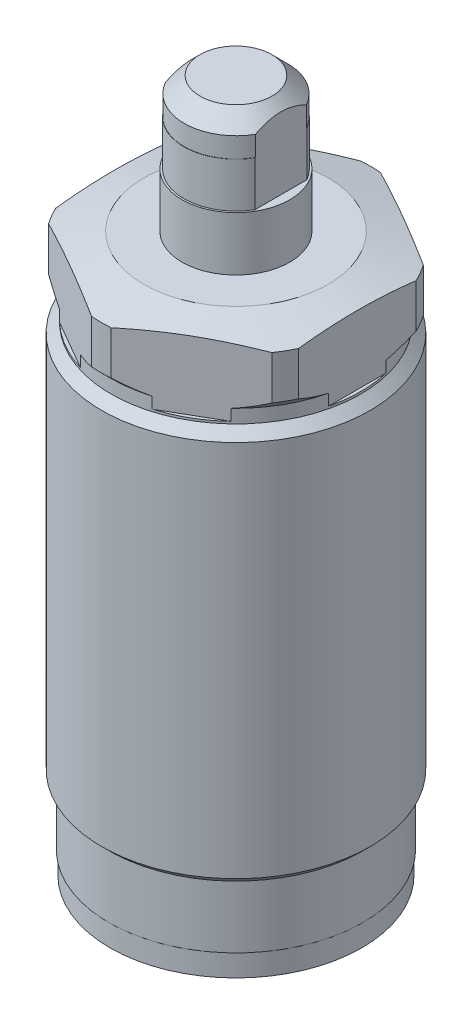
from build123d import *

# Parameters (mm, degrees)
SKETCH1_R          = 15
STOCK_DEPTH        = 29.75
HEX_HEAD_DEPTH     = 8.5
SKETCH5_R          = 14
RETAINER_DEPTH     = 2.5
SKETCH9_W          = 1.368260999
SKETCH9_H          = 3.99
SKETCH9_W_2        = 1.545391276
CUT_EXTRUDE3_DEPTH = 13.475
SKETCH10_R         = 5.98
EXTRUDE4_DEPTH     = 11.01
SKETCH11_R         = 5.98
SKETCH11_R_2       = 5.775
CUT_EXTRUDE4_DEPTH = 5
SKETCH13_W         = 0.98
SKETCH13_H         = 5
CUT_EXTRUDE5_DEPTH = 15


with BuildPart() as part:
    # Sketch1 → STOCK (new body, symmetric)
    with BuildSketch(Plane(origin=(0, 0, 0), x_dir=(1, 0, 0), z_dir=(0, 1, 0))):
        with Locations(Location((0, 0, 0), (0, 0, 270))):  # turned: the seam where the file's is
            Circle(SKETCH1_R)
    extrude(amount=STOCK_DEPTH, both=True)

    # Sketch2 → HEX_HEAD (cut)
    with BuildSketch(Plane(origin=(0, 29.75, 0), x_dir=(1, 0, 0), z_dir=(0, 1, 0))):
        with BuildLine():
            ThreePointArc((12.412375826, 8.422168743), (7.5, 12.990381057), (1.087624174, 14.960517159))
            Line((1.087624174, 14.960517159), (12.412375826, 8.422168743))
        make_face()
        with BuildLine():
            Line((-12.412375826, 8.422168743), (-1.087624174, 14.960517159))
            ThreePointArc((-1.087624174, 14.960517159), (-7.5, 12.990381057), (-12.412375826, 8.422168743))
        make_face()
        with BuildLine():
            Line((13.5, 6.538348415), (13.5, -6.538348415))
            ThreePointArc((13.5, -6.538348415), (15, 0), (13.5, 6.538348415))
        make_face()
        with BuildLine():
            Line((-13.5, -6.538348415), (-13.5, 6.538348415))
            ThreePointArc((-13.5, 6.538348415), (-15, 0), (-13.5, -6.538348415))
        make_face()
        with BuildLine():
            Line((12.412375826, -8.422168743), (1.087624174, -14.960517159))
            ThreePointArc((1.087624174, -14.960517159), (7.5, -12.990381057), (12.412375826, -8.422168743))
        make_face()
        with BuildLine():
            Line((-1.087624174, -14.960517159), (-12.412375826, -8.422168743))
            ThreePointArc((-12.412375826, -8.422168743), (-7.5, -12.990381057), (-1.087624174, -14.960517159))
        make_face()
    extrude(amount=-HEX_HEAD_DEPTH, mode=Mode.SUBTRACT)

    # Sketch3 → CROWN (revolve, cut)
    with BuildSketch(Plane.XY, mode=Mode.PRIVATE) as crown_sk:
        Polygon((10.25, 29.75), (15, 29.75), (15, 28.477241336), align=None)
    revolve(crown_sk.sketch.rotate(Axis((0, 0, 0), (0, 1, 0)), 94.158067237), axis=Axis((0, 0, 0), (0, 1, 0)), mode=Mode.SUBTRACT)  # turned: the seam where the file's is

    # Sketch4 → Cut-Revolve1 (revolve, cut)
    with BuildSketch(Plane.XY, mode=Mode.PRIVATE) as cut_revolve1_sk:
        Polygon((14.125, -29.75), (16.897307641, -29.75), (16.897307641, 25.522307641), (13.875, 22.5), (13.875, 21), (14.925, 19.95), (14.925, -22.04), (14.125, -22.84), align=None)
    revolve(cut_revolve1_sk.sketch.rotate(Axis((0, -34.538461529, 0), (0, 1, 0)), 90), axis=Axis((0, -34.538461529, 0), (0, 1, 0)), mode=Mode.SUBTRACT)  # turned: the seam where the file's is

    # Sketch5 → RETAINER (add)
    with BuildSketch(Plane.XZ.offset(29.75)):
        with Locations(Location((0, 0, 0), (0, 0, 90))):  # turned: the seam where the file's is
            Circle(SKETCH5_R)
    extrude(amount=RETAINER_DEPTH)



with BuildPart() as body_2:
    # Sketch8 → Revolve1 (revolve)
    with BuildSketch(Plane.XY, mode=Mode.PRIVATE) as revolve1_sk:
        Polygon((0, 44.75), (4, 44.75), (5.75, 43), (5.75, 40.76), (0, 40.76), align=None)
    revolve(revolve1_sk.sketch.rotate(Axis((0, 0, 0), (0, 1, 0)), 90), axis=Axis((0, 0, 0), (0, 1, 0)))  # turned: the seam where the file's is

    # Sketch9 → Cut-Extrude3 (cut, symmetric)
    with BuildSketch(Plane.XY):
        with Locations((5.6841305, 42.755)):
            Rectangle(SKETCH9_W, SKETCH9_H)
        with Locations((-5.772695638, 42.755)):
            Rectangle(SKETCH9_W_2, SKETCH9_H)
    extrude(amount=CUT_EXTRUDE3_DEPTH, both=True, mode=Mode.SUBTRACT)


with BuildPart() as part_1:
    add(part.part)

    add(body_2.part)  # Extrude4 merges body 2
    # Sketch10 → Extrude4 (add)
    with BuildSketch(Plane(origin=(0, 29.75, 0), x_dir=(1, 0, 0), z_dir=(0, 1, 0))):
        with Locations(Location((0, 0, 0), (0, 0, 180))):  # turned: the seam where the file's is
            Circle(SKETCH10_R)
    extrude(amount=EXTRUDE4_DEPTH)

    # Sketch11 → Cut-Extrude4 (cut)
    with BuildSketch(Plane(origin=(0, 40.76, 0), x_dir=(1, 0, 0), z_dir=(0, 1, 0))):
        with Locations(Location((0, 0, 0), (0, 0, 180))):  # turned: the seam where the file's is
            Circle(SKETCH11_R)
        with Locations(Location((0, 0, 0), (0, 0, 180))):  # turned: the seam where the file's is
            Circle(SKETCH11_R_2, mode=Mode.SUBTRACT)
    extrude(amount=-CUT_EXTRUDE4_DEPTH, mode=Mode.SUBTRACT)

    # Sketch13 → Cut-Extrude5 (cut, symmetric)
    with BuildSketch(Plane.XY):
        with Locations((5.49, 38.26)):
            Rectangle(SKETCH13_W, SKETCH13_H)
        with Locations((-5.49, 38.26)):
            Rectangle(SKETCH13_W, SKETCH13_H)
    extrude(amount=CUT_EXTRUDE5_DEPTH, both=True, mode=Mode.SUBTRACT)


solid = part_1.part
